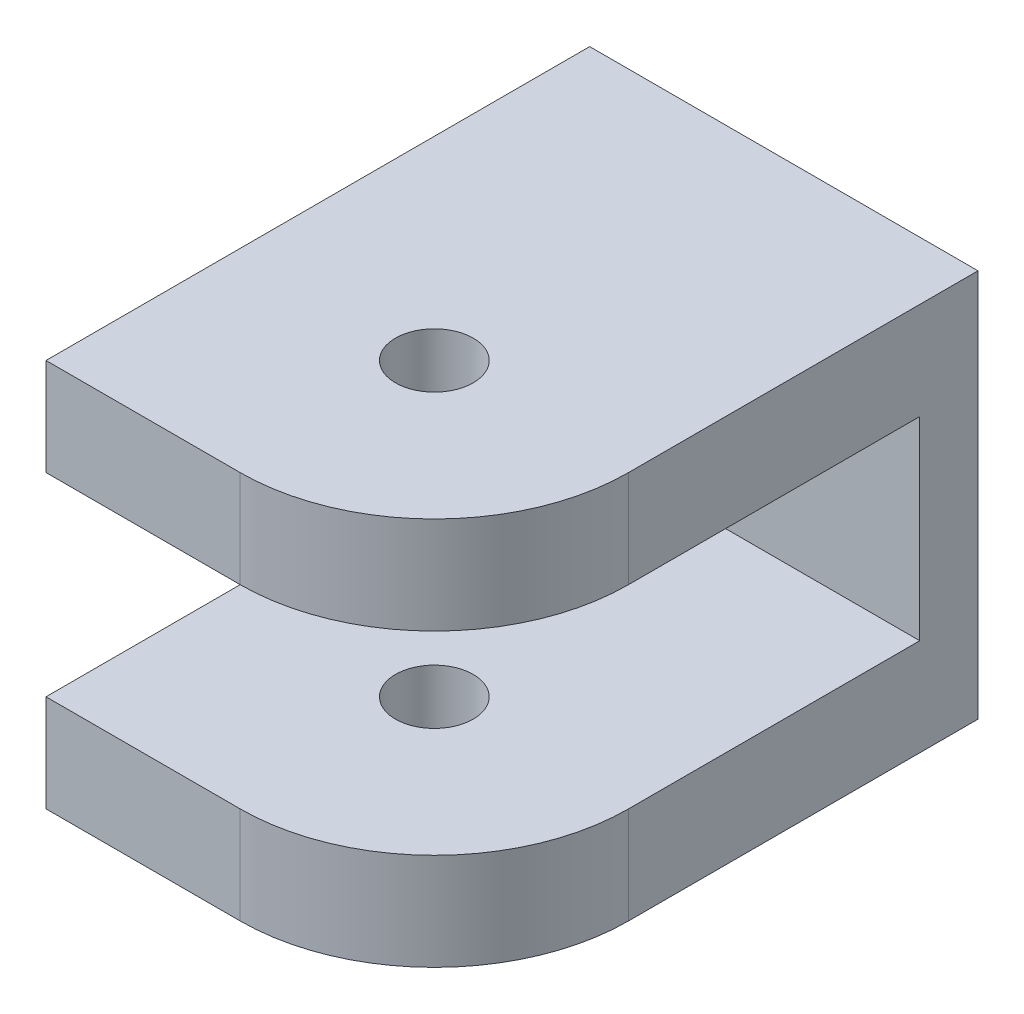
from build123d import *

# Parameters (mm, degrees)
CROQUIS1_W              = 20
CROQUIS1_H              = 20
CROQUIS1_R              = 1.55
SALIENTE_EXTRUIR1_DEPTH = 3
CROQUIS2_W              = 20
CROQUIS2_H              = 5
SALIENTE_EXTRUIR3_DEPTH = 15
SALIENTE_EXTRUIR4_DEPTH = 5
SALIENTE_EXTRUIR5_DEPTH = 5
CROQUIS5_R              = 2
CORTAR_EXTRUIR1_DEPTH   = 21


with BuildPart() as part:
    # Croquis1 → Saliente-Extruir1 (new body)
    with BuildSketch(Plane.XY):
        with Locations((10, 10)):
            Rectangle(CROQUIS1_W, CROQUIS1_H)
        with Locations((10, 10)):
            Circle(CROQUIS1_R, mode=Mode.SUBTRACT)
    extrude(amount=-SALIENTE_EXTRUIR1_DEPTH)

    # Croquis2 → Saliente-Extruir3 (add)
    with BuildSketch(Plane.XY):
        with Locations((10, 2.5)):
            Rectangle(CROQUIS2_W, CROQUIS2_H)
        with Locations((10, 17.5)):
            Rectangle(CROQUIS2_W, CROQUIS2_H)
    extrude(amount=SALIENTE_EXTRUIR3_DEPTH)

    # Croquis3 → Saliente-Extruir4 (add)
    with BuildSketch(Plane(origin=(0, 20, 0), x_dir=(1, 0, 0), z_dir=(0, 1, 0))):
        with BuildLine():
            Line((20, -15), (0, -15))
            Line((0, -15), (0, -25))
            Line((0, -25), (10, -25))
            ThreePointArc((10, -25), (17.071067812, -22.071067812), (20, -15))
        make_face()
    extrude(amount=-SALIENTE_EXTRUIR4_DEPTH)

    # Croquis4 → Saliente-Extruir5 (add)
    with BuildSketch(Plane.XZ):
        with BuildLine():
            Line((0, 15), (20, 15))
            ThreePointArc((20, 15), (17.071067812, 22.071067812), (10, 25))
            Line((10, 25), (0, 25))
            Line((0, 25), (0, 15))
        make_face()
    extrude(amount=-SALIENTE_EXTRUIR5_DEPTH)

    # Croquis5 → Cortar-Extruir1 (cut, through all)
    with BuildSketch(Plane.XZ):
        with Locations((10, 15)):
            Circle(CROQUIS5_R)
    extrude(amount=-CORTAR_EXTRUIR1_DEPTH, mode=Mode.SUBTRACT)


solid = part.part
